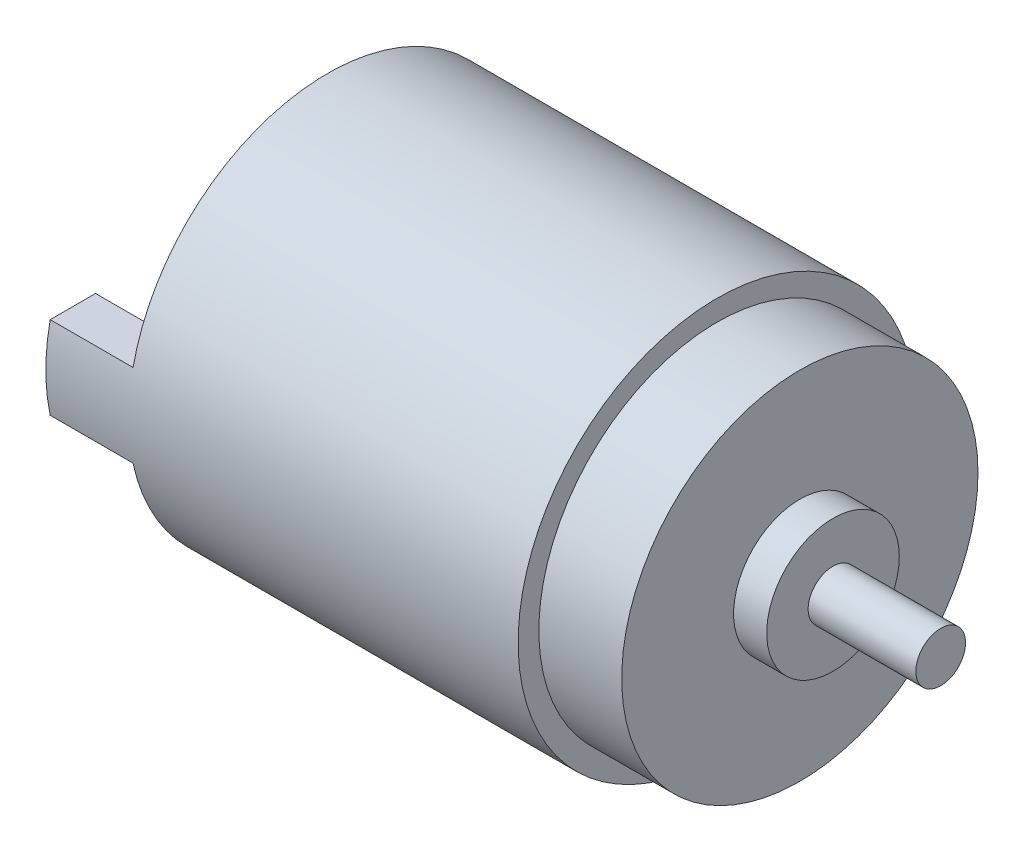
from build123d import *

# Parameters (mm, degrees)
SKETCH_1_R      = 12
EXTRUDE_1_DEPTH = 23.5
SKETCH_2_R      = 1.5
EXTRUDE_2_DEPTH = 13.5
SKETCH_3_R      = 10.75
EXTRUDE_3_DEPTH = 5
SKETCH_4_R      = 4
EXTRUDE_4_DEPTH = 2
EXTRUDE_5_DEPTH = 2
EXTRUDE_6_DEPTH = 5


with BuildPart() as part:
    # 草图1 → 凸台-拉伸1 (new body)
    with BuildSketch(Plane(origin=(0, 0, 0), x_dir=(0, 0, -1), z_dir=(1, 0, 0))):
        Circle(SKETCH_1_R)
    extrude(amount=EXTRUDE_1_DEPTH)

    # 草图2 → 凸台-拉伸2 (add)
    with BuildSketch(Plane(origin=(23.5, 0, 0), x_dir=(0, 0, -1), z_dir=(1, 0, 0))):
        Circle(SKETCH_2_R)
    extrude(amount=EXTRUDE_2_DEPTH)

    # 草图3 → 凸台-拉伸3 (add)
    with BuildSketch(Plane(origin=(23.5, 0, 0), x_dir=(0, 0, -1), z_dir=(1, 0, 0))):
        Circle(SKETCH_3_R)
    extrude(amount=EXTRUDE_3_DEPTH)

    # 草图4 → 凸台-拉伸4 (add)
    with BuildSketch(Plane(origin=(28.5, 0, 0), x_dir=(0, 0, -1), z_dir=(1, 0, 0))):
        Circle(SKETCH_4_R)
    extrude(amount=EXTRUDE_4_DEPTH)

    # 草图5 → 凸台-拉伸5 (add)
    with BuildSketch(Plane.ZY):
        with BuildLine():
            Line((-2.061552813, -4), (2.061552813, -4))
            ThreePointArc((2.061552813, -4), (0, 4.5), (-2.061552813, -4))
        make_face()
    extrude(amount=EXTRUDE_5_DEPTH)

    # 草图6 → 凸台-拉伸6 (add)
    with BuildSketch(Plane.ZY):
        with BuildLine():
            Line((11.736694594, 2.5), (9, 2.5))
            Line((9, 2.5), (9, -2.5))
            Line((9, -2.5), (11.736694594, -2.5))
            ThreePointArc((11.736694594, -2.5), (11.933992105, -1.256913853), (12, 0))
            ThreePointArc((12, 0), (11.933992105, 1.256913853), (11.736694594, 2.5))
        make_face()
    extrude_6 = extrude(amount=EXTRUDE_6_DEPTH)

    # 镜向1: 凸台-拉伸6 across plane
    add(extrude_6.mirror(Plane.XY))


solid = part.part
